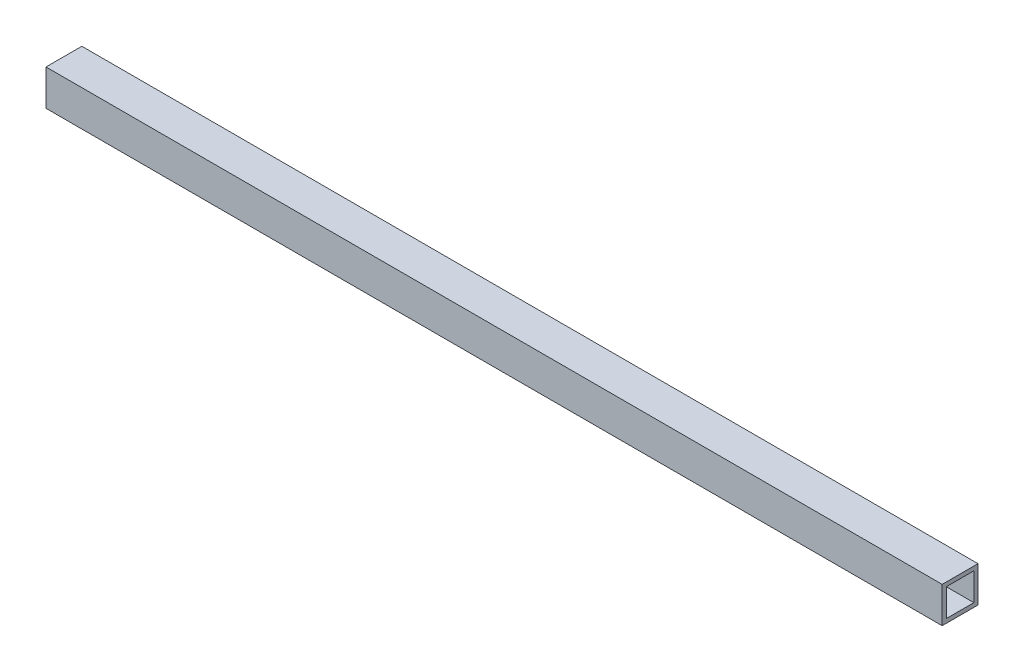
from build123d import *

# Parameters (mm, degrees)
SKETCH1_W           = 650
SKETCH1_H           = 26
BOSS_EXTRUDE1_DEPTH = 26
SHELL1_T            = -3


with BuildPart() as part:
    # Sketch1 → Boss-Extrude1 (new body)
    with BuildSketch(Plane(origin=(0, 0, 0), x_dir=(1, 0, 0), z_dir=(0, 1, 0))):
        Rectangle(SKETCH1_W, SKETCH1_H)
    extrude(amount=BOSS_EXTRUDE1_DEPTH)

    # Shell1
    shell1_openings = [part.faces().sort_by_distance(p)[0] for p in [
        (-325, 13, 0),
        (325, 13, 0),
    ]]
    offset(amount=SHELL1_T, openings=shell1_openings, kind=Kind.INTERSECTION)


solid = part.part
